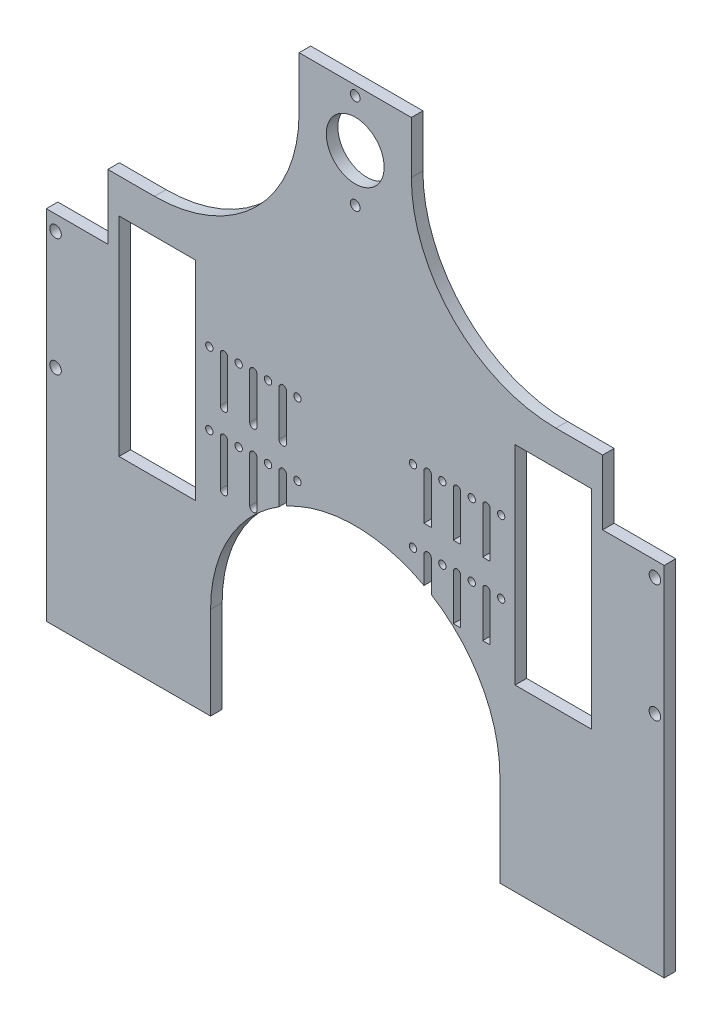
from build123d import *

# Parameters (mm, degrees)
SKETCH1_W           = 267
SKETCH1_H           = 350.4
SKETCH1_R           = 2.1
SKETCH1_R_2         = 2.5
SKETCH1_R_3         = 1.59
SKETCH1_R_4         = 12.5
SKETCH1_W_2         = 33
SKETCH1_H_2         = 90
BOSS_EXTRUDE1_DEPTH = 5
SKETCH12_W          = 267
SKETCH12_H          = 5
CUT_EXTRUDE2_DEPTH  = 83
CUT_EXTRUDE3_DEPTH  = 6
SKETCH15_W          = 28.794476706
SKETCH15_H          = 22.5
SKETCH15_W_2        = 7.746360579
CUT_EXTRUDE4_DEPTH  = 10


with BuildPart() as part:
    # Sketch1 → Boss-Extrude1 (new body)
    with BuildSketch(Plane.XY):
        with Locations((133.5, -175.2)):
            Rectangle(SKETCH1_W, SKETCH1_H)
        with Locations((133.5, -45)):
            Circle(SKETCH1_R, mode=Mode.SUBTRACT)
        with Locations((133.5, -4)):
            Circle(SKETCH1_R, mode=Mode.SUBTRACT)
        with Locations((263, -119.5)):
            Circle(SKETCH1_R_2, mode=Mode.SUBTRACT)
        with Locations((263, -170.5)):
            Circle(SKETCH1_R_2, mode=Mode.SUBTRACT)
        with Locations((196.56, -129.375)):
            Circle(SKETCH1_R_3, mode=Mode.SUBTRACT)
        with Locations((196.56, -160.625)):
            Circle(SKETCH1_R_3, mode=Mode.SUBTRACT)
        with Locations((133.5, -24.5)):
            Circle(SKETCH1_R_4, mode=Mode.SUBTRACT)
        with Locations((158.46, -129.375)):
            Circle(SKETCH1_R_3, mode=Mode.SUBTRACT)
        with Locations((171.16, -129.375)):
            Circle(SKETCH1_R_3, mode=Mode.SUBTRACT)
        with Locations((183.86, -129.375)):
            Circle(SKETCH1_R_3, mode=Mode.SUBTRACT)
        with Locations((158.46, -160.625)):
            Circle(SKETCH1_R_3, mode=Mode.SUBTRACT)
        with Locations((171.16, -160.625)):
            Circle(SKETCH1_R_3, mode=Mode.SUBTRACT)
        with Locations((183.86, -160.625)):
            Circle(SKETCH1_R_3, mode=Mode.SUBTRACT)
        with Locations((83.14, -160.625)):
            Circle(SKETCH1_R_3, mode=Mode.SUBTRACT)
        with Locations((95.84, -160.625)):
            Circle(SKETCH1_R_3, mode=Mode.SUBTRACT)
        with Locations((108.54, -160.625)):
            Circle(SKETCH1_R_3, mode=Mode.SUBTRACT)
        with Locations((83.14, -129.375)):
            Circle(SKETCH1_R_3, mode=Mode.SUBTRACT)
        with Locations((95.84, -129.375)):
            Circle(SKETCH1_R_3, mode=Mode.SUBTRACT)
        with Locations((108.54, -129.375)):
            Circle(SKETCH1_R_3, mode=Mode.SUBTRACT)
        with Locations((70.44, -160.625)):
            Circle(SKETCH1_R_3, mode=Mode.SUBTRACT)
        with Locations((70.44, -129.375)):
            Circle(SKETCH1_R_3, mode=Mode.SUBTRACT)
        with Locations((4, -170.5)):
            Circle(SKETCH1_R_2, mode=Mode.SUBTRACT)
        with Locations((4, -119.5)):
            Circle(SKETCH1_R_2, mode=Mode.SUBTRACT)
        with Locations((219.06, -145)):
            Rectangle(SKETCH1_W_2, SKETCH1_H_2, mode=Mode.SUBTRACT)
        with BuildLine():
            Line((163.2225, -129.375), (163.2225, -149.054634918))
            ThreePointArc((163.2225, -149.054634918), (164.81, -149.140223925), (166.3975, -149.054634918))
            Line((166.3975, -149.054634918), (166.3975, -129.375))
            ThreePointArc((166.3975, -129.375), (164.81, -127.7875), (163.2225, -129.375))
        make_face(mode=Mode.SUBTRACT)
        with BuildLine():
            Line((175.92, -129.375), (175.92, -149.054634918))
            ThreePointArc((175.92, -149.054634918), (177.51, -149.140492925), (179.1, -149.054634918))
            Line((179.1, -149.054634918), (179.1, -129.375))
            ThreePointArc((179.1, -129.375), (177.51, -127.785), (175.92, -129.375))
        make_face(mode=Mode.SUBTRACT)
        with BuildLine():
            Line((188.62, -129.375), (188.62, -149.054634918))
            ThreePointArc((188.62, -149.054634918), (190.21, -149.140492925), (191.8, -149.054634918))
            Line((191.8, -149.054634918), (191.8, -129.375))
            ThreePointArc((191.8, -129.375), (190.21, -127.785), (188.62, -129.375))
        make_face(mode=Mode.SUBTRACT)
        with BuildLine():
            Line((163.2225, -160.625), (163.2225, -180.304634918))
            ThreePointArc((163.2225, -180.304634918), (164.81, -180.390223925), (166.3975, -180.304634918))
            Line((166.3975, -180.304634918), (166.3975, -160.625))
            ThreePointArc((166.3975, -160.625), (164.81, -159.0375), (163.2225, -160.625))
        make_face(mode=Mode.SUBTRACT)
        with BuildLine():
            Line((175.92, -160.625), (175.92, -180.304634918))
            ThreePointArc((175.92, -180.304634918), (177.51, -180.390492925), (179.1, -180.304634918))
            Line((179.1, -180.304634918), (179.1, -160.625))
            ThreePointArc((179.1, -160.625), (177.51, -159.035), (175.92, -160.625))
        make_face(mode=Mode.SUBTRACT)
        with BuildLine():
            Line((188.62, -160.625), (188.62, -180.304634918))
            ThreePointArc((188.62, -180.304634918), (190.21, -180.390492925), (191.8, -180.304634918))
            Line((191.8, -180.304634918), (191.8, -160.625))
            ThreePointArc((191.8, -160.625), (190.21, -159.035), (188.62, -160.625))
        make_face(mode=Mode.SUBTRACT)
        with BuildLine():
            Line((103.7775, -129.375), (103.7775, -149.054634918))
            ThreePointArc((103.7775, -149.054634918), (102.19, -150.642134918), (100.6025, -149.054634918))
            Line((100.6025, -149.054634918), (100.6025, -129.375))
            ThreePointArc((100.6025, -129.375), (102.19, -127.7875), (103.7775, -129.375))
        make_face(mode=Mode.SUBTRACT)
        with BuildLine():
            Line((91.08, -129.375), (91.08, -149.054634918))
            ThreePointArc((91.08, -149.054634918), (89.49, -150.644634918), (87.9, -149.054634918))
            Line((87.9, -149.054634918), (87.9, -129.375))
            ThreePointArc((87.9, -129.375), (89.49, -127.785), (91.08, -129.375))
        make_face(mode=Mode.SUBTRACT)
        with BuildLine():
            Line((78.38, -129.375), (78.38, -149.054634918))
            ThreePointArc((78.38, -149.054634918), (76.79, -150.644634918), (75.2, -149.054634918))
            Line((75.2, -149.054634918), (75.2, -129.375))
            ThreePointArc((75.2, -129.375), (76.79, -127.785), (78.38, -129.375))
        make_face(mode=Mode.SUBTRACT)
        with BuildLine():
            Line((103.7775, -160.625), (103.7775, -180.304634918))
            ThreePointArc((103.7775, -180.304634918), (102.19, -181.892134918), (100.6025, -180.304634918))
            Line((100.6025, -180.304634918), (100.6025, -160.625))
            ThreePointArc((100.6025, -160.625), (102.19, -159.0375), (103.7775, -160.625))
        make_face(mode=Mode.SUBTRACT)
        with BuildLine():
            Line((91.08, -160.625), (91.08, -180.304634918))
            ThreePointArc((91.08, -180.304634918), (89.49, -181.894634918), (87.9, -180.304634918))
            Line((87.9, -180.304634918), (87.9, -160.625))
            ThreePointArc((87.9, -160.625), (89.49, -159.035), (91.08, -160.625))
        make_face(mode=Mode.SUBTRACT)
        with BuildLine():
            Line((78.38, -160.625), (78.38, -180.304634918))
            ThreePointArc((78.38, -180.304634918), (76.79, -181.894634918), (75.2, -180.304634918))
            Line((75.2, -180.304634918), (75.2, -160.625))
            ThreePointArc((75.2, -160.625), (76.79, -159.035), (78.38, -160.625))
        make_face(mode=Mode.SUBTRACT)
        with Locations((47.94, -145)):
            Rectangle(SKETCH1_W_2, SKETCH1_H_2, mode=Mode.SUBTRACT)
    extrude(amount=BOSS_EXTRUDE1_DEPTH)

    # Sketch12 → Cut-Extrude2 (cut)
    with BuildSketch(Plane.XZ.offset(350.4)):
        with Locations((133.5, 2.5)):
            Rectangle(SKETCH12_W, SKETCH12_H)
    extrude(amount=-CUT_EXTRUDE2_DEPTH, mode=Mode.SUBTRACT)

    # Sketch13 → Cut-Extrude3 (cut, through all)
    with BuildSketch(Plane.XY.offset(5)):
        with BuildLine():
            Line((46.750392508, -85), (26.604338358, -85))
            Line((26.604338358, -85), (26.604338358, -113))
            Line((26.604338358, -113), (0, -113))
            Line((0, -113), (0, 0))
            Line((0, 0), (105.059911457, 0))
            ThreePointArc((105.059911457, 0), (98.289212828, -57.855339059), (46.750392508, -85))
        make_face()
        with BuildLine():
            Line((267, 0), (267, -113))
            Line((267, -113), (240.395661642, -113))
            Line((240.395661642, -113), (240.395661642, -85))
            Line((240.395661642, -85), (220.249607492, -85))
            ThreePointArc((220.249607492, -85), (168.710787172, -57.855339059), (161.940088543, 0))
            Line((161.940088543, 0), (267, 0))
        make_face()
        with BuildLine():
            Line((71, -227.4), (71, -350.4))
            Line((71, -350.4), (196, -350.4))
            Line((196, -350.4), (196, -227.4))
            ThreePointArc((196, -227.4), (133.5, -164.9), (71, -227.4))
        make_face()
    extrude(amount=-CUT_EXTRUDE3_DEPTH, mode=Mode.SUBTRACT)

    # Sketch15 → Cut-Extrude4 (cut)
    with BuildSketch(Plane.XY.offset(5)):
        with Locations((94.853154155, -11.25)):
            Rectangle(SKETCH15_W, SKETCH15_H)
        with Locations((161.622787782, -11.25)):
            Rectangle(SKETCH15_W_2, SKETCH15_H)
    extrude(amount=-CUT_EXTRUDE4_DEPTH, mode=Mode.SUBTRACT)


solid = part.part
